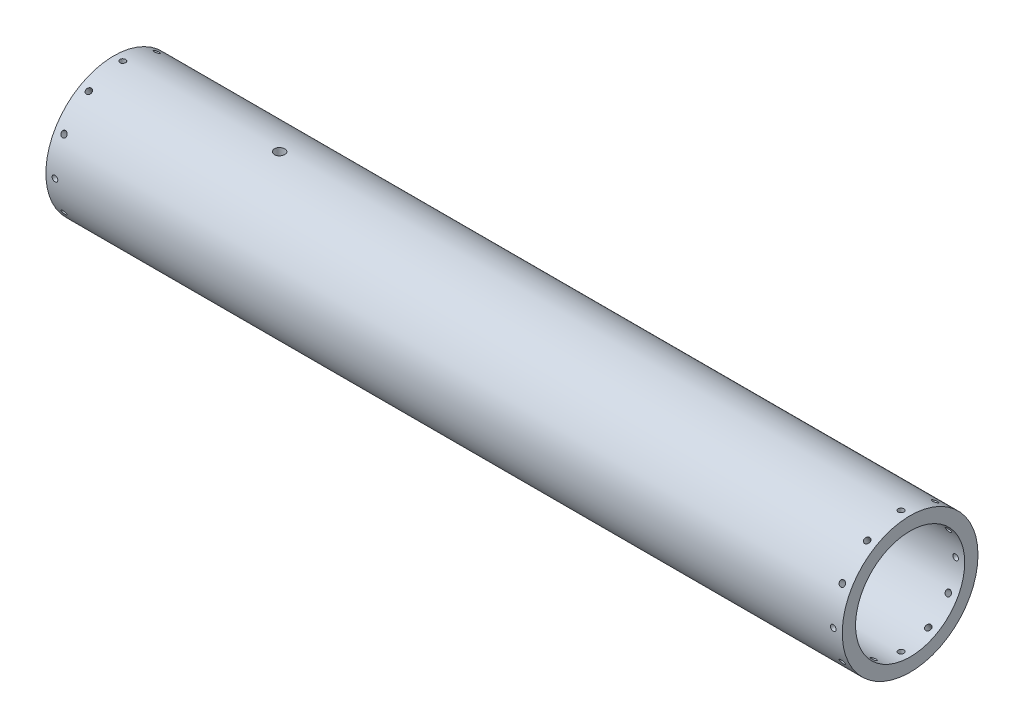
from build123d import *

# Parameters (mm, degrees)
SKETCH1_R           = 57.15
SKETCH1_R_2         = 45.9486
BOSS_EXTRUDE1_DEPTH = 670.56
SKETCH6_R           = 2.413
CUT_EXTRUDE1_DEPTH  = 15.24
SKETCH7_R           = 2.413
CUT_EXTRUDE2_DEPTH  = 15.24
CIRPATTERN2_COUNT   = 12
CIRPATTERN3_COUNT   = 12
SKETCH8_R           = 4.3053
CUT_EXTRUDE3_DEPTH  = 115.300000101


with BuildPart() as part:
    # Sketch1 → Boss-Extrude1 (new body)
    with BuildSketch(Plane(origin=(0, 0, 0), x_dir=(0, 0, -1), z_dir=(1, 0, 0))):
        Circle(SKETCH1_R)
        Circle(SKETCH1_R_2, mode=Mode.SUBTRACT)
    extrude(amount=BOSS_EXTRUDE1_DEPTH)

    # Sketch6 → Cut-Extrude1 (cut)
    with BuildSketch(Plane(origin=(0, 57.15, 0), x_dir=(1, 0, 0), z_dir=(0, 1, 0))):
        with Locations((7.62, 0)):
            Circle(SKETCH6_R)
    cut_extrude1 = extrude(amount=-CUT_EXTRUDE1_DEPTH, mode=Mode.SUBTRACT)

    # Sketch7 → Cut-Extrude2 (cut)
    with BuildSketch(Plane(origin=(0, 57.15, 0), x_dir=(1, 0, 0), z_dir=(0, 1, 0))):
        with Locations((662.94, 0)):
            Circle(SKETCH7_R)
    cut_extrude2 = extrude(amount=-CUT_EXTRUDE2_DEPTH, mode=Mode.SUBTRACT)

    # CirPattern2: Cut-Extrude2 ×12 about axis
    cirpattern2_axis = Axis((670.56, 0, 0), (1, 0, 0))
    for i in range(1, CIRPATTERN2_COUNT):
        add(cut_extrude2.rotate(cirpattern2_axis, i * 360 / CIRPATTERN2_COUNT), mode=Mode.SUBTRACT)

    # CirPattern3: Cut-Extrude1 ×12 about axis
    cirpattern3_axis = Axis((0, 0, 0), (-1, 0, 0))
    for i in range(1, CIRPATTERN3_COUNT):
        add(cut_extrude1.rotate(cirpattern3_axis, i * 360 / CIRPATTERN3_COUNT), mode=Mode.SUBTRACT)

    # Sketch8 → Cut-Extrude3 (cut, through all)
    with BuildSketch(Plane(origin=(0, 57.15, 0), x_dir=(1, 0, 0), z_dir=(0, 1, 0))):
        with Locations((139.7, 0)):
            Circle(SKETCH8_R)
    extrude(amount=-CUT_EXTRUDE3_DEPTH, mode=Mode.SUBTRACT)


solid = part.part
